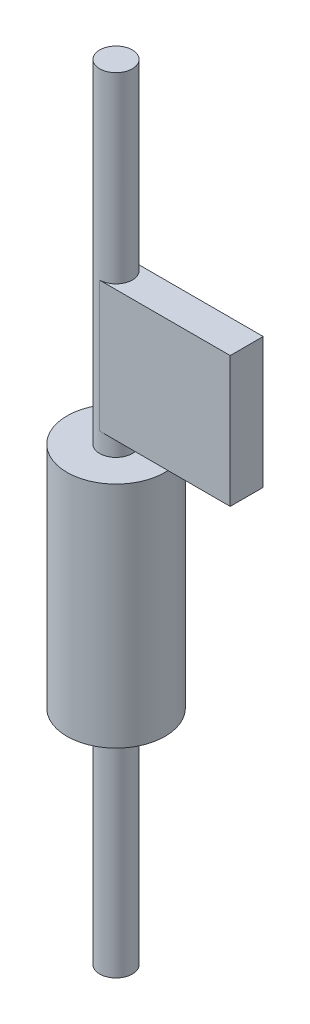
from build123d import *

# Parameters (mm, degrees)
SKETCH1_R           = 3.175
BOSS_EXTRUDE1_DEPTH = 152.4
SKETCH2_W           = 6.4135
SKETCH2_H           = 25.4
BOSS_EXTRUDE2_DEPTH = 25.4
SKETCH4_R           = 9.525
BOSS_EXTRUDE3_DEPTH = 44.45


with BuildPart() as part:
    # Sketch1 → Boss-Extrude1 (new body)
    with BuildSketch(Plane(origin=(0, 0, 0), x_dir=(1, 0, 0), z_dir=(0, 1, 0))):
        Circle(SKETCH1_R)
    extrude(amount=BOSS_EXTRUDE1_DEPTH)

    # Sketch2 → Boss-Extrude2 (add)
    with BuildSketch(Plane(origin=(0, 0, 0), x_dir=(0, 0, -1), z_dir=(1, 0, 0))):
        with Locations((0, 104.14)):
            Rectangle(SKETCH2_W, SKETCH2_H)
    extrude(amount=BOSS_EXTRUDE2_DEPTH)

    # Sketch4 → Boss-Extrude3 (add)
    with BuildSketch(Plane(origin=(0, 43.18, 0), x_dir=(1, 0, 0), z_dir=(0, 1, 0))):
        Circle(SKETCH4_R)
    extrude(amount=BOSS_EXTRUDE3_DEPTH)


solid = part.part
